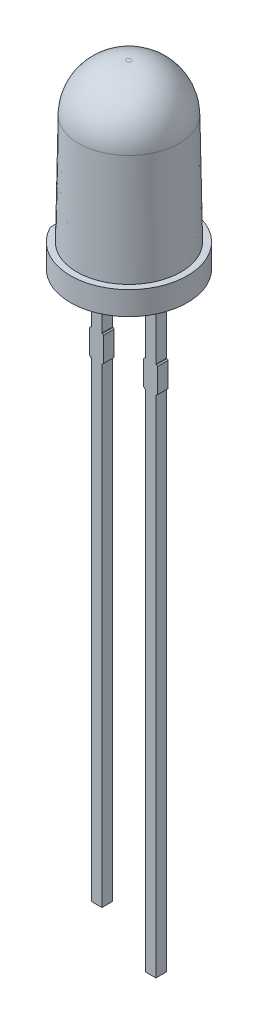
from build123d import *

# Parameters (mm, degrees)
SKETCH1_R           = 2.75
BOSS_EXTRUDE1_DEPTH = 1.1
SKETCH2_R           = 2.45
DRAFT1_ANGLE        = 1
FILLET1_R           = 2.25
CUT_EXTRUDE1_DEPTH  = 1.1
SKETCH6_W           = 0.5
SKETCH6_H           = 0.5
BOSS_EXTRUDE2_DEPTH = 28
MOVE_FACE1_BY       = 1.6
SKETCH7_W           = 0.65
SKETCH7_H           = 1.25
BOSS_EXTRUDE3_DEPTH = 0.5
CHAMFER1_SIZE       = 0.05


with BuildPart() as part:
    # Sketch1 → Boss-Extrude1 (new body)
    with BuildSketch(Plane(origin=(0, 0, 0), x_dir=(1, 0, 0), z_dir=(0, 1, 0))):
        with Locations(Location((0, 0, 0), (0, 0, 270))):
            Circle(SKETCH1_R)
    extrude(amount=BOSS_EXTRUDE1_DEPTH)

    # Sweep1: sweep along a path in Sketch3
    with BuildLine(Plane.XY) as sweep1_path:
        Line((0, 1.1), (0, 8.5))
    # Sketch2 → Sweep1 (sweep)
    with BuildSketch(Plane(origin=(0, 1.1, 0), x_dir=(1, 0, 0), z_dir=(0, 1, 0))):
        Circle(SKETCH2_R)
    sweep(path=sweep1_path.line)

    # Draft1
    draft1_faces = [part.faces().sort_by_distance(p)[0] for p in [
        (-2.45, 4.8, 0),
    ]]
    draft(draft1_faces, Plane.ZX.offset(1.1), DRAFT1_ANGLE)

    # Fillet1
    fillet1_edges = [part.edges().sort_by_distance(p)[0] for p in [
        (-2.32083252, 8.5, 0),
    ]]
    fillet(fillet1_edges, radius=FILLET1_R)

    # Sketch5 → Cut-Extrude1 (cut)
    with BuildSketch(Plane(origin=(0, 1.1, 0), x_dir=(1, 0, 0), z_dir=(0, 1, 0))):
        with BuildLine():
            Line((-2.45, 1.2489996), (-2.45, -1.2489996))
            ThreePointArc((-2.45, -1.2489996), (-2.75, 0), (-2.45, 1.2489996))
        make_face()
    extrude(amount=-CUT_EXTRUDE1_DEPTH, mode=Mode.SUBTRACT)

    # Sketch6 → Boss-Extrude2 (add)
    with BuildSketch(Plane.XZ):
        with Locations((-1.27, 0)):
            Rectangle(SKETCH6_W, SKETCH6_H)
        with Locations((1.27, 0)):
            Rectangle(SKETCH6_W, SKETCH6_H)
    extrude(amount=BOSS_EXTRUDE2_DEPTH)

    # Move Face1: a face moved inward by 1.6
    extrude(part.faces().sort_by_distance((-1.27, -28, 0))[0], amount=MOVE_FACE1_BY, dir=(0, 1, 0), mode=Mode.SUBTRACT)

    # Sketch7 → Boss-Extrude3 (add)
    with BuildSketch(Plane.XY.offset(0.25)):
        with Locations((1.27, -3.625)):
            Rectangle(SKETCH7_W, SKETCH7_H)
        with Locations((-1.27, -3.625)):
            Rectangle(SKETCH7_W, SKETCH7_H)
    extrude(amount=-BOSS_EXTRUDE3_DEPTH)

    # Chamfer1
    chamfer1_edges = [part.edges().sort_by_distance(p)[0] for p in [
        (0.945, -3, 0),
        (1.595, -4.25, 0),
        (0.945, -4.25, 0),
        (1.595, -3, 0),
        (-1.595, -3, 0),
        (-0.945, -4.25, 0),
        (-1.595, -4.25, 0),
        (-0.945, -3, 0),
    ]]
    chamfer(chamfer1_edges, length=CHAMFER1_SIZE)


solid = part.part
